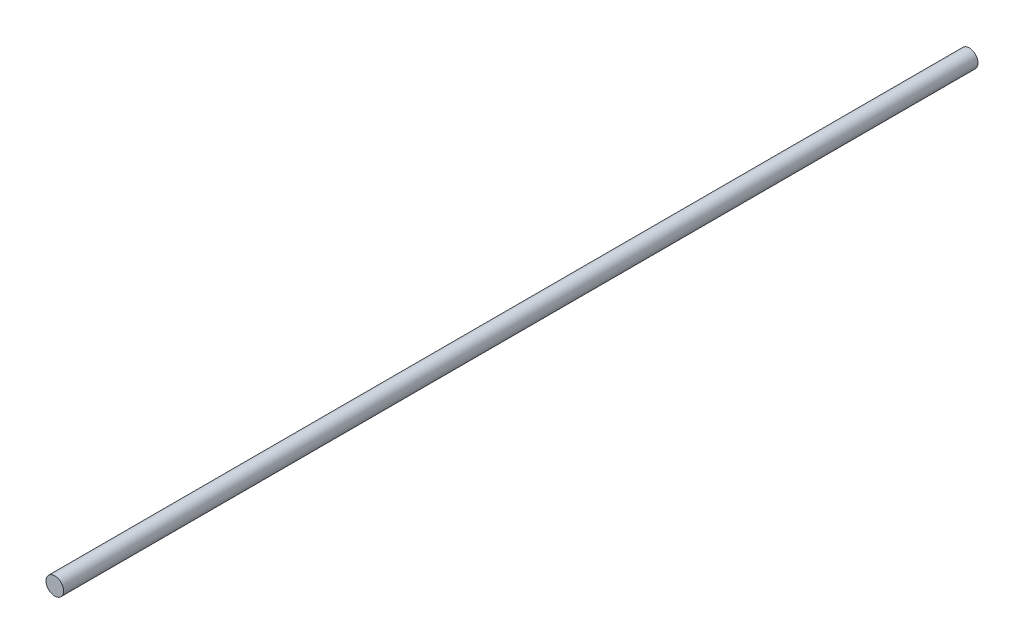
from build123d import *

# Parameters (mm, degrees)
SKETCH1_R           = 2.5
BOSS_EXTRUDE1_DEPTH = 260


with BuildPart() as part:
    # Sketch1 → Boss-Extrude1 (new body)
    with BuildSketch(Plane.XY):
        Circle(SKETCH1_R)
    extrude(amount=BOSS_EXTRUDE1_DEPTH)


solid = part.part
